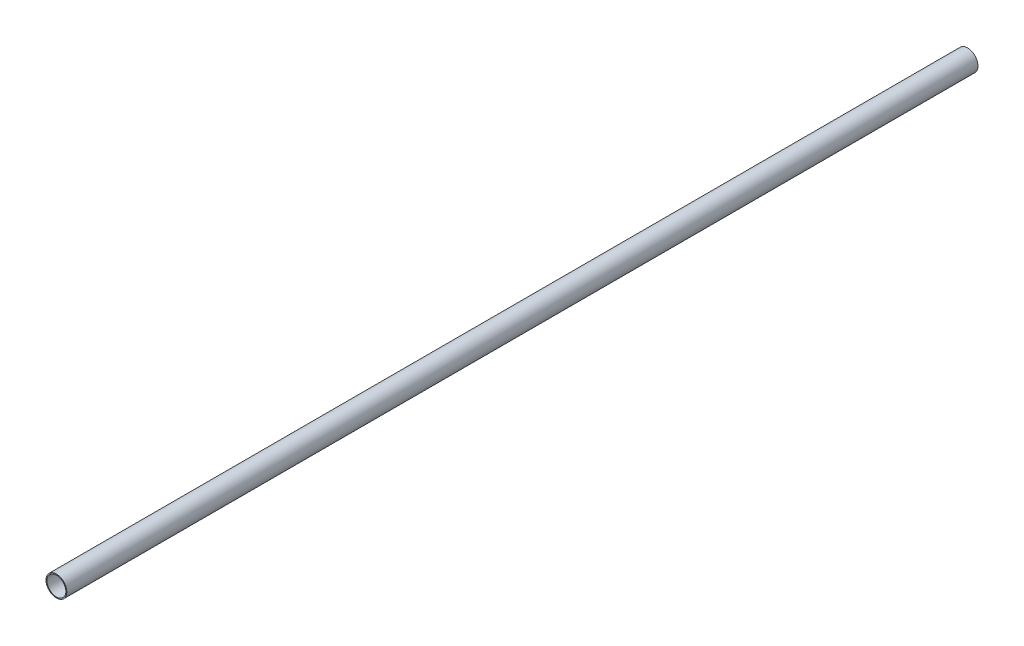
from build123d import *

# Parameters (mm, degrees)
ESQUISSE1_R        = 16
ESQUISSE1_R_2      = 14.5
BOSS_EXTRU_1_DEPTH = 1400


with BuildPart() as part:
    # Esquisse1 → Boss.-Extru.1 (new body)
    with BuildSketch(Plane.XY):
        Circle(ESQUISSE1_R)
        Circle(ESQUISSE1_R_2, mode=Mode.SUBTRACT)
    extrude(amount=BOSS_EXTRU_1_DEPTH)


solid = part.part
